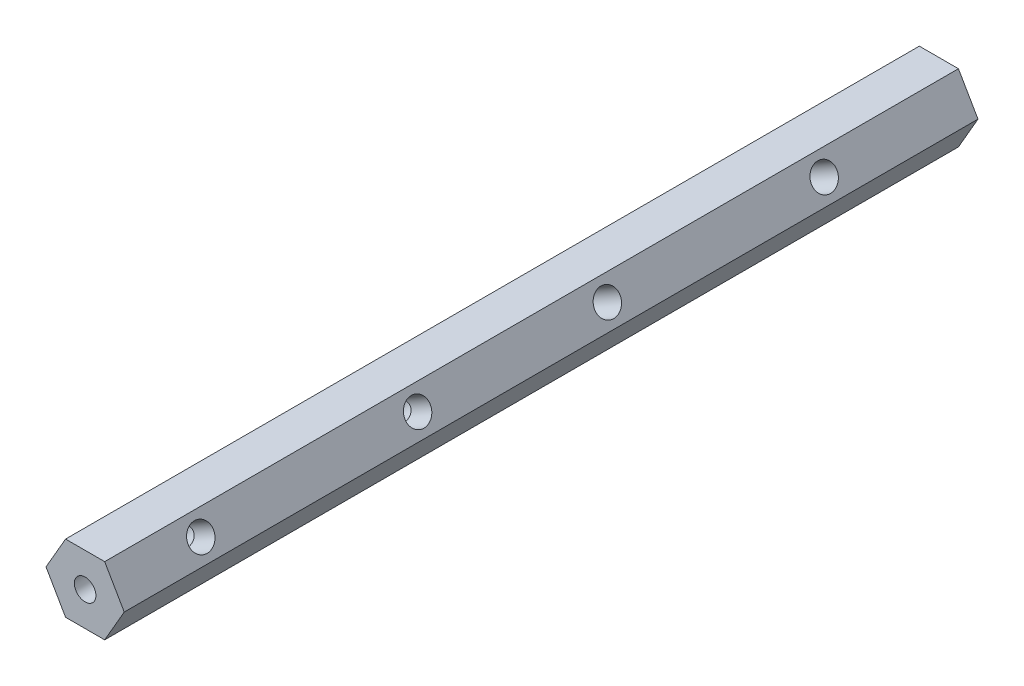
from build123d import *

# Parameters (mm, degrees)
BOSS_EXTRUDE1_DEPTH        = 160.02
F_10_32_TAPPED_HOLE1_D     = 4.0386
F_10_32_TAPPED_HOLE1_DEPTH = 76.2
F_10_32_TAPPED_HOLE1_TIP   = 1.213317848
SKETCH5_R                  = 2.38125
CUT_EXTRUDE1_DEPTH         = 4.175
CUT_EXTRUDE1_DEPTH_BACK    = 16.875


with BuildPart() as part:
    # Sketch1 → Boss-Extrude1 (new body)
    with BuildSketch(Plane.XY):
        Polygon((7.332348419, 0), (3.666174209, 6.35), (-3.666174209, 6.35), (-7.332348419, 0), (-3.666174209, -6.35), (3.666174209, -6.35), align=None)
    extrude(amount=BOSS_EXTRUDE1_DEPTH)

    # #10-32 Tapped Hole1
    with Locations(Plane.XY.offset(160.02)):
        with Locations((0, 0)):
            Hole(F_10_32_TAPPED_HOLE1_D / 2, depth=F_10_32_TAPPED_HOLE1_DEPTH)
            with Locations((0, 0, -(F_10_32_TAPPED_HOLE1_DEPTH + F_10_32_TAPPED_HOLE1_TIP / 2))):  # 118° drill point
                Cone(0, F_10_32_TAPPED_HOLE1_D / 2, F_10_32_TAPPED_HOLE1_TIP, mode=Mode.SUBTRACT)

    # Sketch5 → Cut-Extrude1 (cut, two sides)
    with BuildSketch(Plane(origin=(5.499261314, 3.175, 0), x_dir=(0, 0, -1), z_dir=(0.866025404, 0.5, 0))) as cut_extrude1_sk:
        with Locations((-27.0002, 0)):
            Circle(SKETCH5_R)
        with Locations((-67.6402, 0)):
            Circle(SKETCH5_R)
        with Locations((-103.2002, 0)):
            Circle(SKETCH5_R)
        with Locations((-143.8402, 0)):
            Circle(SKETCH5_R)
    extrude(amount=CUT_EXTRUDE1_DEPTH, mode=Mode.SUBTRACT)
    extrude(cut_extrude1_sk.sketch, amount=-CUT_EXTRUDE1_DEPTH_BACK, mode=Mode.SUBTRACT)


solid = part.part
